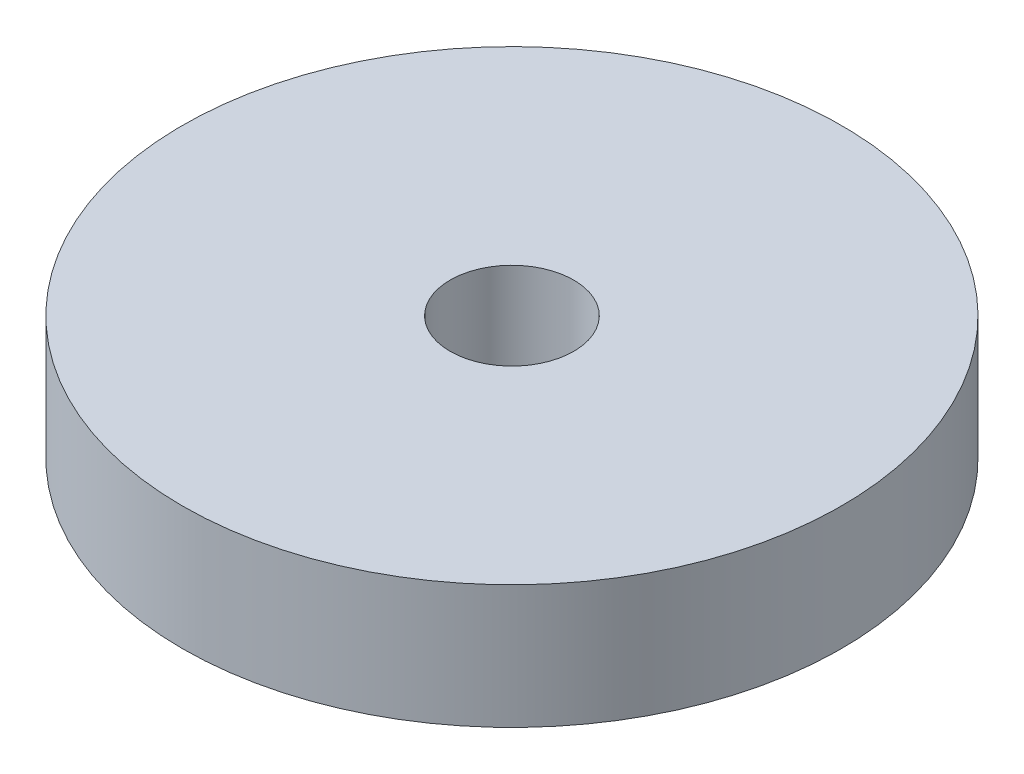
from build123d import *

# Parameters (mm, degrees)
SKETCH1_R           = 25.4
SKETCH1_R_2         = 4.7625
BOSS_EXTRUDE1_DEPTH = 4.7625


with BuildPart() as part:
    # Sketch1 → Boss-Extrude1 (new body, symmetric)
    with BuildSketch(Plane(origin=(0, 0, 0), x_dir=(1, 0, 0), z_dir=(0, 1, 0))):
        Circle(SKETCH1_R)
        Circle(SKETCH1_R_2, mode=Mode.SUBTRACT)
    extrude(amount=BOSS_EXTRUDE1_DEPTH, both=True)


solid = part.part
